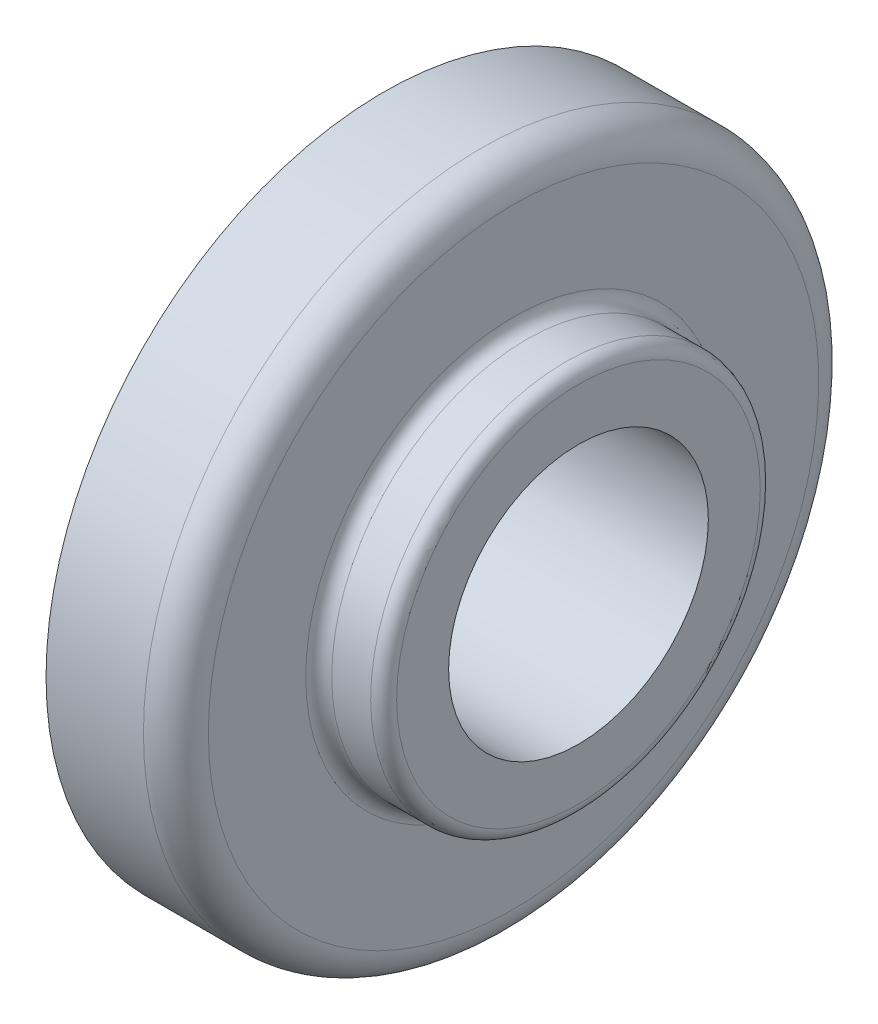
from build123d import *

# Parameters (mm, degrees)
SKETCH2_R      = 10
EXTRUDE1_DEPTH = 16


with BuildPart() as part:
    # Sketch1 → Revolve1 (revolve)
    with BuildSketch(Plane(origin=(0, 0, 0), x_dir=(1, 0, 0), z_dir=(0, 1, 0))):
        with BuildLine():
            Line((-2.818193867, -7.327304055), (1.105880126, -7.327304055))
            Line((1.105880126, -7.327304055), (12.181806133, -7.327304055))
            Line((12.181806133, -7.327304055), (12.181806133, 6.672695945))
            ThreePointArc((12.181806133, 6.672695945), (11.888912914, 7.379802726), (11.181806133, 7.672695945))
            Line((11.181806133, 7.672695945), (8.181806133, 7.672695945))
            ThreePointArc((8.181806133, 7.672695945), (7.474699351, 7.965589164), (7.181806133, 8.672695945))
            Line((7.181806133, 8.672695945), (7.181806133, 16.172695945))
            ThreePointArc((7.181806133, 16.172695945), (6.449573086, 17.940462898), (4.681806133, 18.672695945))
            Line((4.681806133, 18.672695945), (-2.818193867, 18.672695945))
            Line((-2.818193867, 18.672695945), (-2.818193867, -7.327304055))
        make_face()
    revolve(axis=Axis((-2.818193867, 0, 7.327304055), (1, 0, 0)))

    # Sketch2 → Extrude1 (cut, through all)
    with BuildSketch(Plane(origin=(12.181806133, 0, 0), x_dir=(0, 0, -1), z_dir=(1, 0, 0))):
        with Locations((-7.327304055, 0)):
            Circle(SKETCH2_R)
    extrude(amount=-EXTRUDE1_DEPTH, mode=Mode.SUBTRACT)


solid = part.part
